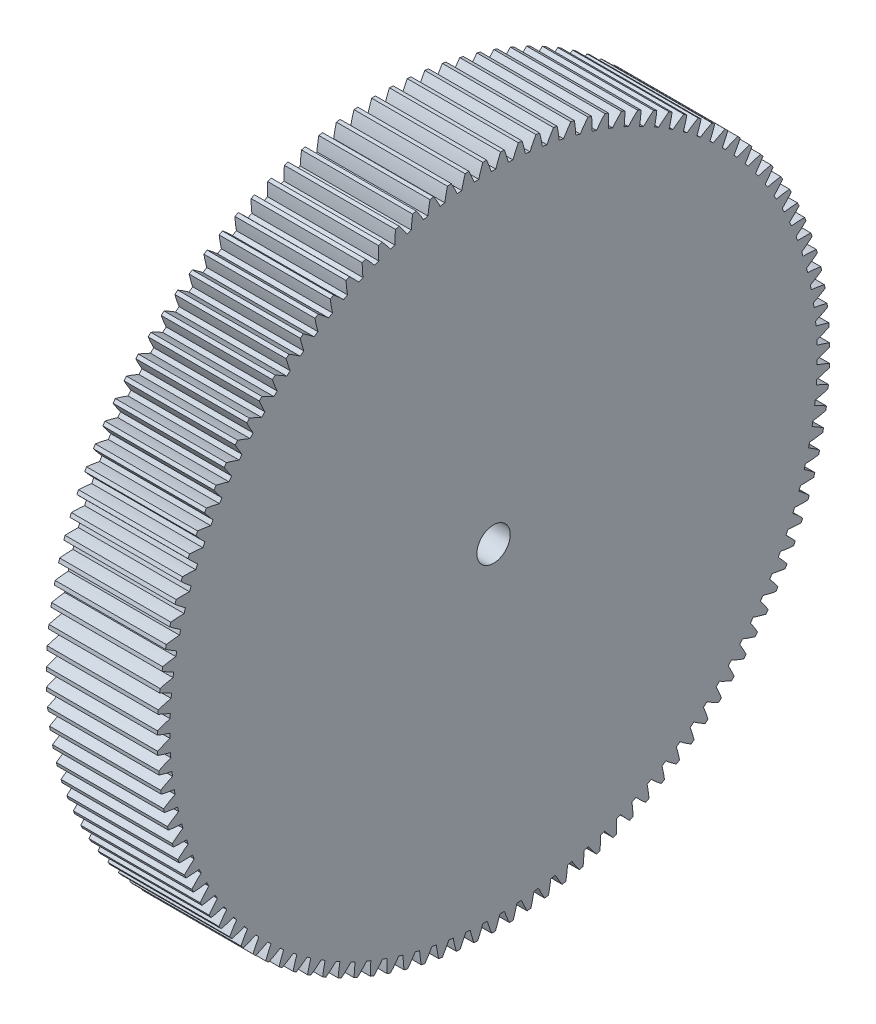
from build123d import *

# Parameters (mm, degrees)
BASPROSKE_W     = 10
BASPROSKE_H     = 30.25
TOOTHCUT_DEPTH  = 44.933187911
TEETHCUTS_COUNT = 119
TEETHCUTS_ANGLE = 356.974789916
BORSKE_R        = 1.5
BORE_DEPTH      = 50.0000508


with BuildPart() as part:
    # BasProSke → Base-Revolve (revolve)
    with BuildSketch(Plane(origin=(0, 0, 0), x_dir=(1, 0, 0), z_dir=(0, 1, 0)), mode=Mode.PRIVATE) as base_revolve_sk:
        with Locations((5, 15.125)):
            Rectangle(BASPROSKE_W, BASPROSKE_H)
    revolve(base_revolve_sk.sketch.rotate(Axis((-10, 0, 0), (1, 0, 0)), 180), axis=Axis((-10, 0, 0), (1, 0, 0)))

    # TooCutSke → ToothCut (cut, through all)
    with BuildSketch(Plane(origin=(0, 0, 0), x_dir=(0, 0, -1), z_dir=(1, 0, 0))):
        with BuildLine():
            ThreePointArc((0.205279347, 29.123276539), (0, 29.124), (-0.205279347, 29.123276539))
            ThreePointArc((-0.205279347, 29.123276539), (-0.408549368, 29.701558615), (-0.641327068, 30.268606588))
            ThreePointArc((-0.641327068, 30.268606588), (0, 30.2754), (0.641327068, 30.268606588))
            ThreePointArc((0.641327068, 30.268606588), (0.408549368, 29.701558615), (0.205279347, 29.123276539))
        make_face()
    toothcut = extrude(amount=TOOTHCUT_DEPTH, mode=Mode.SUBTRACT)

    # TeethCuts: ToothCut ×119 about axis
    teethcuts_axis = Axis((-10, 0, 0), (1, 0, 0))
    for i in range(1, TEETHCUTS_COUNT):
        add(toothcut.rotate(teethcuts_axis, i * TEETHCUTS_ANGLE / (TEETHCUTS_COUNT - 1)), mode=Mode.SUBTRACT)

    # BorSke → Bore (cut, symmetric)
    with BuildSketch(Plane(origin=(0, 0, 0), x_dir=(0, 0, -1), z_dir=(1, 0, 0))):
        with Locations(Location((0, 0, 0), (0, 0, 180))):
            Circle(BORSKE_R)
    extrude(amount=BORE_DEPTH, both=True, mode=Mode.SUBTRACT)


solid = part.part
